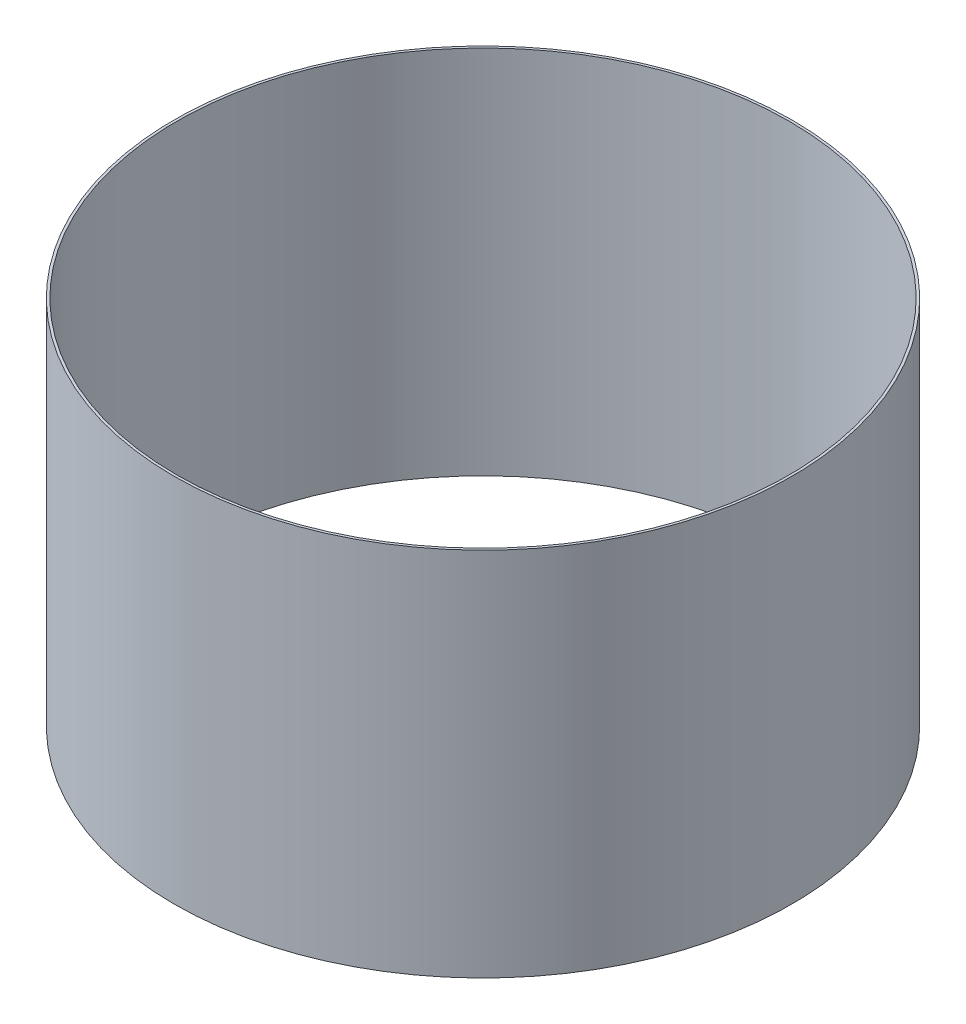
from build123d import *

# Parameters (mm, degrees)
SKETCH1_W = 2
SKETCH1_H = 300


with BuildPart() as part:
    # Sketch1 → Revolve1 (revolve)
    with BuildSketch(Plane.XY):
        with Locations((-249, 150)):
            Rectangle(SKETCH1_W, SKETCH1_H)
    revolve(axis=Axis((0, 0, 0), (0, -1, 0)))


solid = part.part
